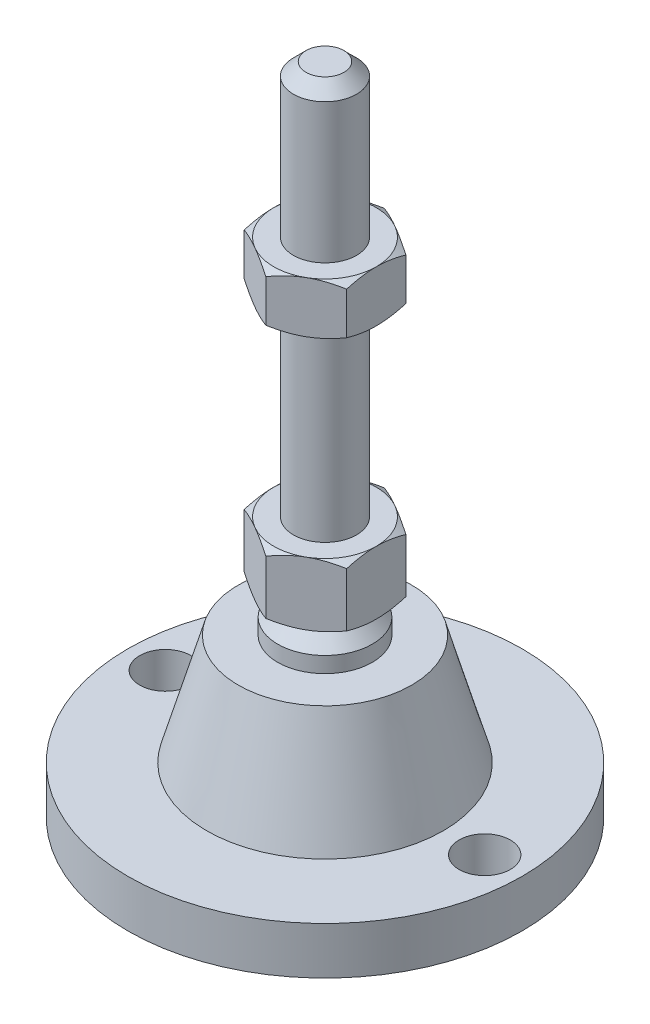
from build123d import *

# Parameters (mm, degrees)
EXTRUDE_1_DEPTH     = 8
EXTRUDE_2_DEPTH     = 6.5
SKETCH_5_R          = 3.25
CUT_EXTRUDE_1_DEPTH = 7


with BuildPart() as part:
    # Эскиз1 → Повернуть1 (revolve)
    with BuildSketch(Plane.XY, mode=Mode.PRIVATE) as revolve_1_sk:
        Polygon((0, 0), (-25, 0), (-25, 6), (-15, 6), (-11, 20), (-6, 20), (-6, 22), (-4, 24), (-4, 25), (-4, 33), (-4, 81.4), (-2.4, 83), (0, 83), align=None)
    revolve(revolve_1_sk.sketch.rotate(Axis((0, 0, 0), (0, 1, 0)), 180), axis=Axis((0, 0, 0), (0, 1, 0)))  # turned: the seam where the file's is

    # Эскиз2 → Бобышка-Вытянуть1 (add)
    with BuildSketch(Plane(origin=(0, 25, 0), x_dir=(1, 0, 0), z_dir=(0, 1, 0))):
        Polygon((0, 7.505553499), (-6.5, 3.75277675), (-6.5, -3.75277675), (0, -7.505553499), (6.5, -3.75277675), (6.5, 3.75277675), align=None)
    extrude(amount=EXTRUDE_1_DEPTH)

    # Эскиз3 → Бобышка-Вытянуть2 (add)
    with BuildSketch(Plane(origin=(0, 57.2, 0), x_dir=(1, 0, 0), z_dir=(0, 1, 0))):
        Polygon((6.5, 3.75277675), (0, 7.505553499), (-6.5, 3.75277675), (-6.5, -3.75277675), (0, -7.505553499), (6.5, -3.75277675), align=None)
    extrude(amount=EXTRUDE_2_DEPTH)

    # Эскиз4 → Вырез-Повернуть2 (revolve, cut)
    with BuildSketch(Plane.XY, mode=Mode.PRIVATE) as cut_revolve_2_sk:
        Polygon((-12.129165125, 63.7), (-6.5, 63.7), (-12.129165125, 60.45), align=None)
        Polygon((-12.129165125, 57.2), (-12.129165125, 60.45), (-6.5, 57.2), align=None)
        Polygon((-13.42820323, 33), (-13.42820323, 29), (-6.5, 33), align=None)
        Polygon((-13.42820323, 29), (-13.42820323, 25), (-6.5, 25), align=None)
    revolve(cut_revolve_2_sk.sketch.rotate(Axis((0, 83, 0), (0, 1, 0)), 180), axis=Axis((0, 83, 0), (0, 1, 0)), mode=Mode.SUBTRACT)  # turned: the seam where the file's is

    # Эскиз5 → Вырез-Вытянуть1 (cut, through all)
    with BuildSketch(Plane(origin=(0, 6, 0), x_dir=(1, 0, 0), z_dir=(0, 1, 0))):
        with Locations(Location((-20.25, 0, 0), (0, 0, 180))):  # turned: the seam where the file's is
            Circle(SKETCH_5_R)
        with Locations(Location((20.25, 0, 0), (0, 0, 180))):  # turned: the seam where the file's is
            Circle(SKETCH_5_R)
    extrude(amount=-CUT_EXTRUDE_1_DEPTH, mode=Mode.SUBTRACT)


solid = part.part
